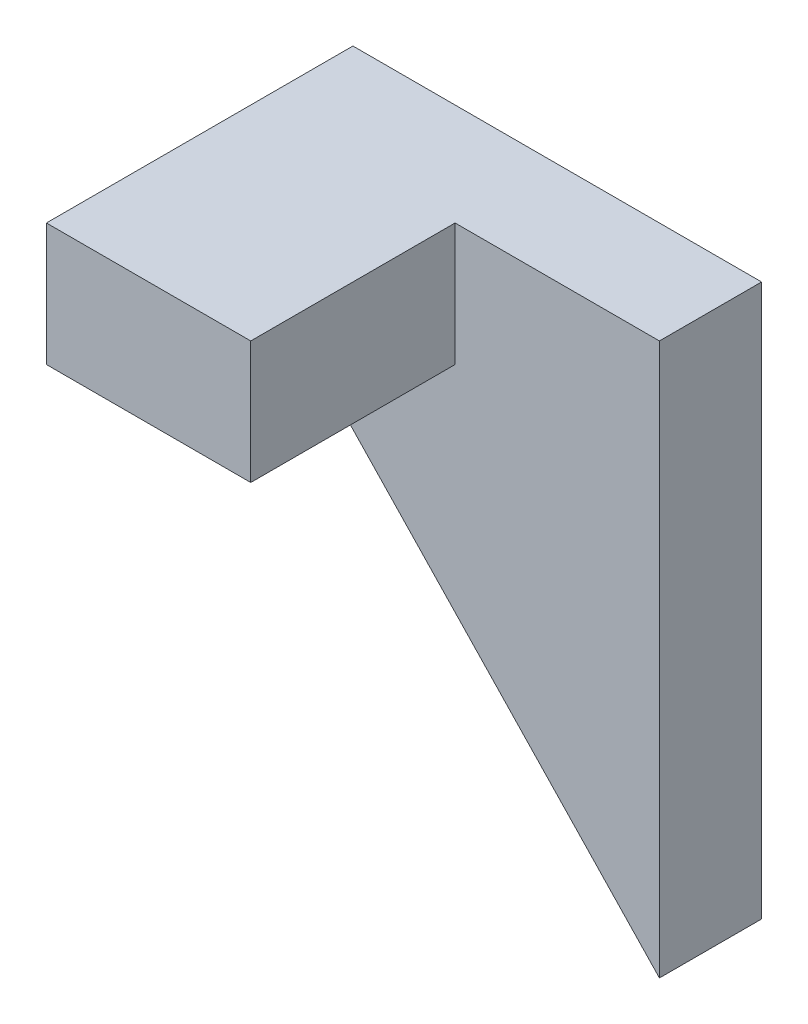
from build123d import *

# Parameters (mm, degrees)
BOSS_EXTRUDE1_DEPTH = 10
SKETCH1_4_W         = 20
SKETCH1_4_H         = 12
BOSS_EXTRUDE2_DEPTH = 30


with BuildPart() as part:
    # Sketch1 → Boss-Extrude1 (new body)
    with BuildSketch(Plane.XY):
        Polygon((20, -12), (0, -12), (40, -54), (40, 0), (20, 0), align=None)
    extrude(amount=BOSS_EXTRUDE1_DEPTH)

    # Sketch1_4 → Boss-Extrude2 (add)
    with BuildSketch(Plane.XY):
        with Locations((10, -6)):
            Rectangle(SKETCH1_4_W, SKETCH1_4_H)
    extrude(amount=BOSS_EXTRUDE2_DEPTH)


solid = part.part
